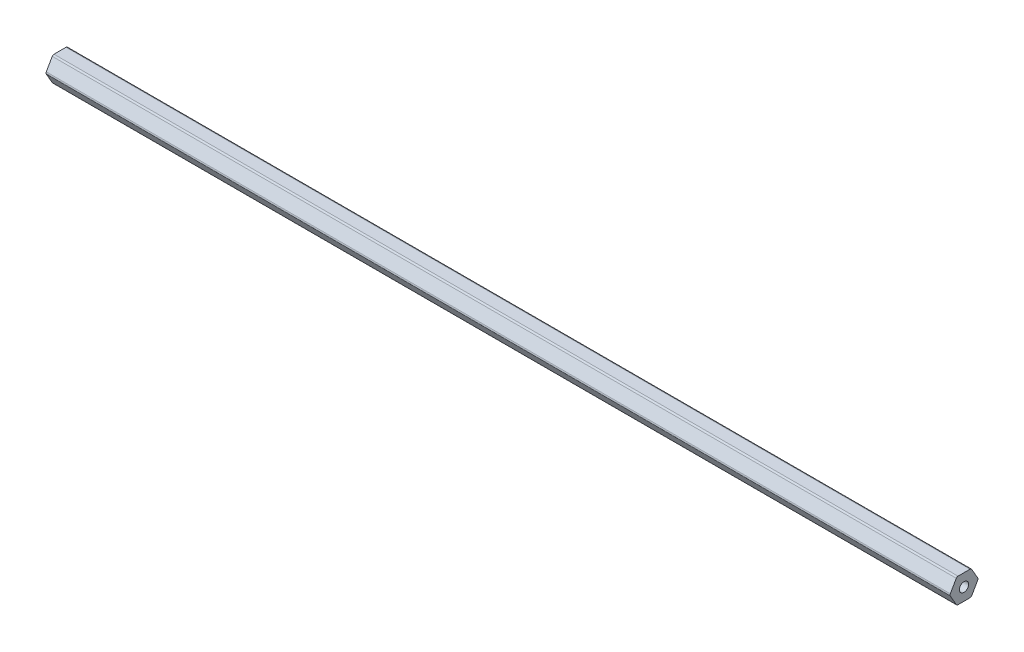
from build123d import *

# Parameters (mm, degrees)
SKETCH1_R                = 2.38125
BOSS_EXTRUDE1_DEPTH      = 231.775
BOSS_EXTRUDE1_DEPTH_BACK = 231.775


with BuildPart() as part:
    # Sketch1 → Boss-Extrude1 (new body, two sides)
    with BuildSketch(Plane(origin=(0, 0, 0), x_dir=(0, 0, -1), z_dir=(1, 0, 0))) as boss_extrude1_sk:
        with BuildLine():
            Line((7.039054482, 0.508), (3.959468146, 5.842))
            ThreePointArc((3.959468146, 5.842), (3.587586336, 6.21388181), (3.079586336, 6.35))
            Line((3.079586336, 6.35), (-3.079586336, 6.35))
            ThreePointArc((-3.079586336, 6.35), (-3.587586336, 6.21388181), (-3.959468146, 5.842))
            Line((-3.959468146, 5.842), (-7.039054482, 0.508))
            ThreePointArc((-7.039054482, 0.508), (-7.175172672, 0), (-7.039054482, -0.508))
            Line((-7.039054482, -0.508), (-3.959468146, -5.842))
            ThreePointArc((-3.959468146, -5.842), (-3.587586336, -6.21388181), (-3.079586336, -6.35))
            Line((-3.079586336, -6.35), (3.079586336, -6.35))
            ThreePointArc((3.079586336, -6.35), (3.587586336, -6.21388181), (3.959468146, -5.842))
            Line((3.959468146, -5.842), (7.039054482, -0.508))
            ThreePointArc((7.039054482, -0.508), (7.175172672, 0), (7.039054482, 0.508))
        make_face()
        Circle(SKETCH1_R, mode=Mode.SUBTRACT)
    extrude(amount=BOSS_EXTRUDE1_DEPTH)
    extrude(boss_extrude1_sk.sketch, amount=-BOSS_EXTRUDE1_DEPTH_BACK)


solid = part.part
